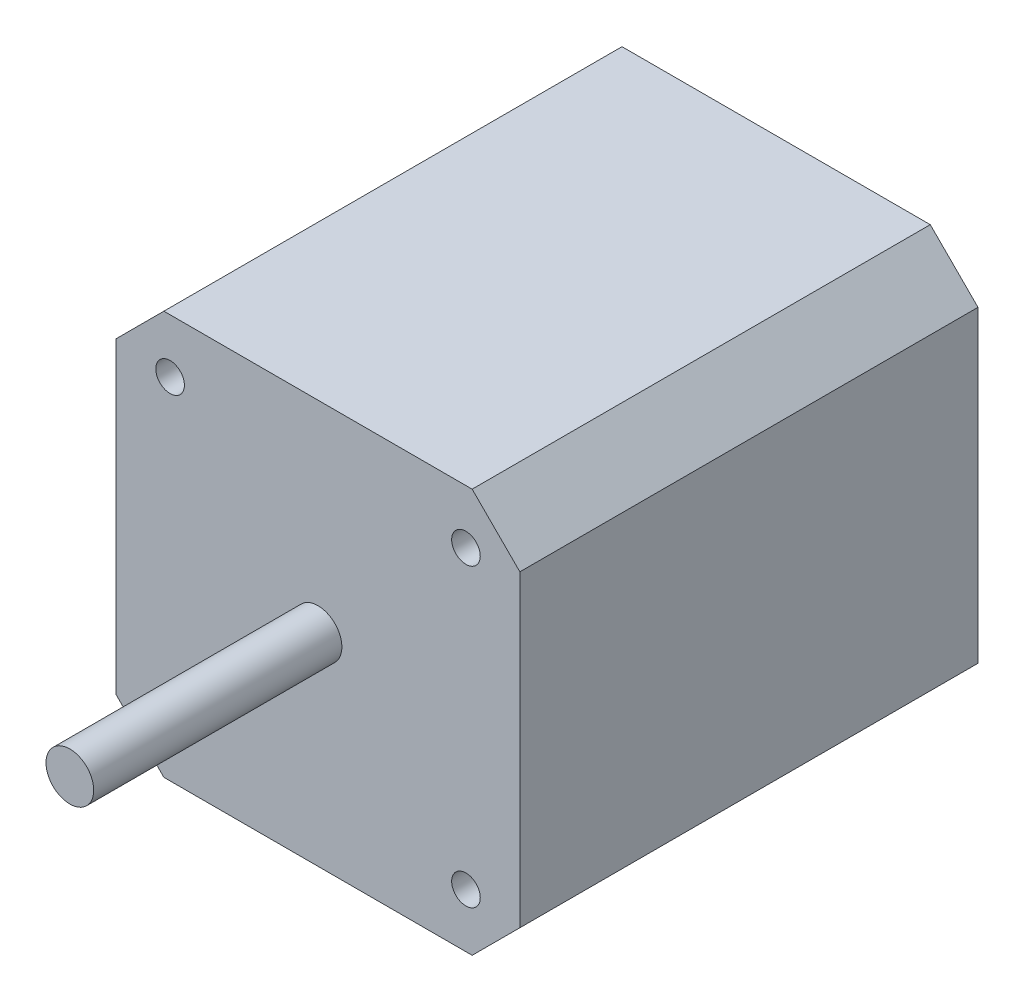
from build123d import *

# Parameters (mm, degrees)
SCHIZZO1_W                   = 42.3
SCHIZZO1_H                   = 42.3
ESTRUSIONE_ESTRUSIONE1_DEPTH = 48
SMUSSO1_SIZE                 = 5
SCHIZZO2_R                   = 2.5
ESTRUSIONE_ESTRUSIONE2_DEPTH = 26
SCHIZZO3_W                   = 2.3
SCHIZZO3_H                   = 15
ESTRUSIONE_ESTRUSIONE3_DEPTH = 5
SCHIZZO4_R                   = 1.5
TAGLIO_ESTRUSIONE1_DEPTH     = 5


with BuildPart() as part:
    # Schizzo1 → Estrusione-Estrusione1 (new body)
    with BuildSketch(Plane.XY):
        Rectangle(SCHIZZO1_W, SCHIZZO1_H)
    extrude(amount=ESTRUSIONE_ESTRUSIONE1_DEPTH)

    # Smusso1
    smusso1_edges = [part.edges().sort_by_distance(p)[0] for p in [
        (21.15, -21.15, 24),
        (-21.15, -21.15, 24),
        (-21.15, 21.15, 24),
        (21.15, 21.15, 24),
    ]]
    chamfer(smusso1_edges, length=SMUSSO1_SIZE)

    # Schizzo2 → Estrusione-Estrusione2 (add)
    with BuildSketch(Plane.XY.offset(48)):
        Circle(SCHIZZO2_R)
    extrude(amount=ESTRUSIONE_ESTRUSIONE2_DEPTH)

    # Schizzo3 → Estrusione-Estrusione3 (add)
    with BuildSketch(Plane(origin=(0, 0, 0), x_dir=(-1, 0, 0), z_dir=(0, 0, -1))):
        with Locations((0, -28.65)):
            Rectangle(SCHIZZO3_W, SCHIZZO3_H)
    extrude(amount=-ESTRUSIONE_ESTRUSIONE3_DEPTH)

    # Schizzo4 → Taglio-Estrusione1 (cut)
    with BuildSketch(Plane.XY.offset(48)):
        with Locations((-15.5, 15.5)):
            Circle(SCHIZZO4_R)
        with Locations((-15.5, -15.5)):
            Circle(SCHIZZO4_R)
        with Locations((15.5, -15.5)):
            Circle(SCHIZZO4_R)
        with Locations((15.5, 15.5)):
            Circle(SCHIZZO4_R)
    extrude(amount=-TAGLIO_ESTRUSIONE1_DEPTH, mode=Mode.SUBTRACT)


solid = part.part
